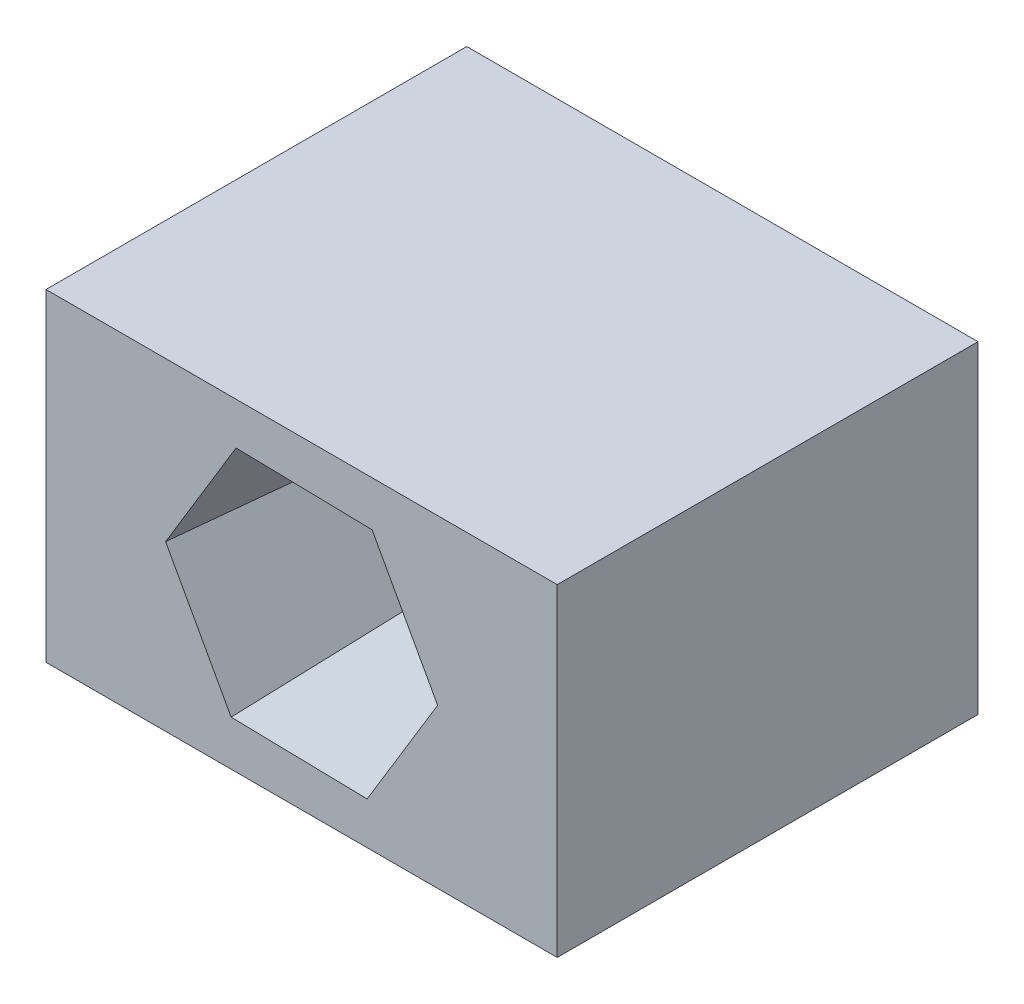
from build123d import *

# Parameters (mm, degrees)
ESQUISSE1_W             = 12.149550462
ESQUISSE1_H             = 7.67378493
ESQUISSE1_R             = 1.7
BOSS_EXTRU_1_DEPTH      = 10
ENL_V_MAT_EXTRU_1_DEPTH = 5
ENL_V_MAT_EXTRU_1_TAPER = 5


with BuildPart() as part:
    # Esquisse1 → Boss.-Extru.1 (new body)
    with BuildSketch(Plane.XY):
        Rectangle(ESQUISSE1_W, ESQUISSE1_H)
        Circle(ESQUISSE1_R, mode=Mode.SUBTRACT)
    extrude(amount=BOSS_EXTRU_1_DEPTH)

    # Esquisse2 → Enlèv. mat.-Extru.1 (cut)
    with BuildSketch(Plane.XY.offset(10)):
        Polygon((1.675518047, 2.765135188), (-1.556918294, 2.833608787), (-3.232436341, 0.068473599), (-1.675518047, -2.765135188), (1.556918294, -2.833608787), (3.232436341, -0.068473599), align=None)
    extrude(amount=-ENL_V_MAT_EXTRU_1_DEPTH, taper=ENL_V_MAT_EXTRU_1_TAPER, mode=Mode.SUBTRACT)


solid = part.part
